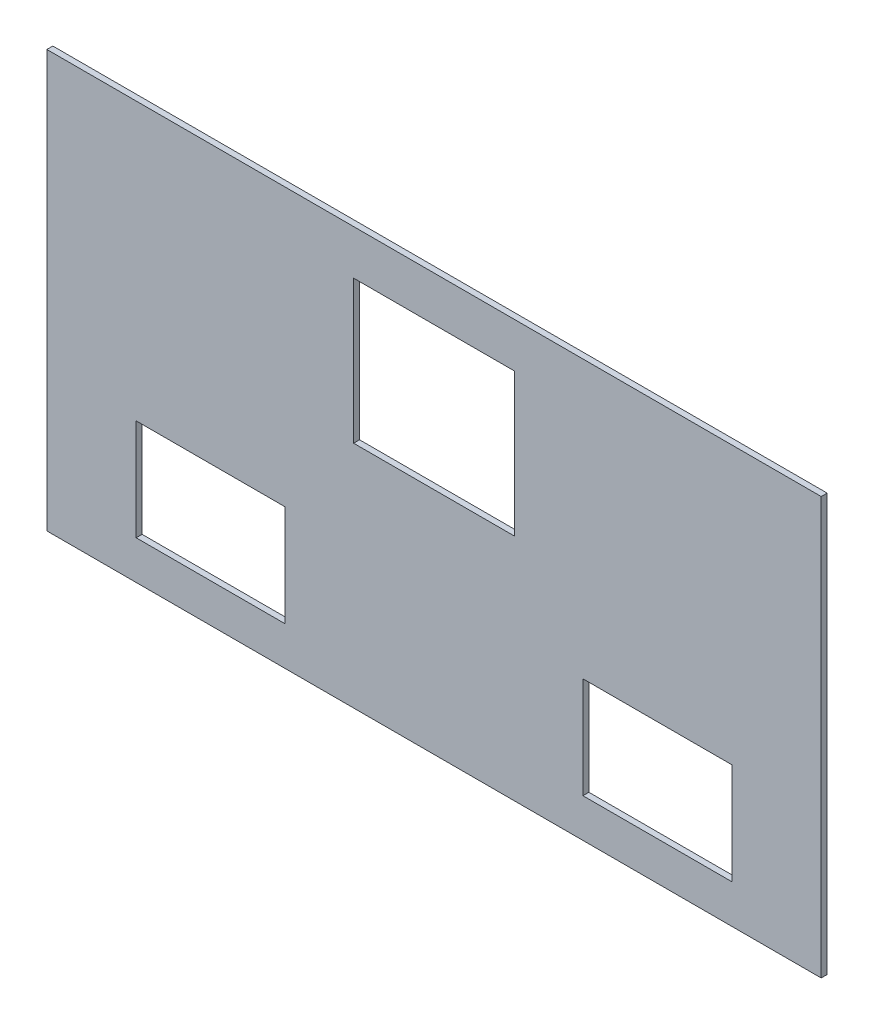
from build123d import *

# Parameters (mm, degrees)
SKETCH1_W           = 130
SKETCH1_H           = 70
BOSS_EXTRUDE1_DEPTH = 1
SKETCH2_W           = 25
SKETCH2_H           = 17
SKETCH2_W_2         = 27
SKETCH2_H_2         = 24
CUT_EXTRUDE1_DEPTH  = 2


with BuildPart() as part:
    # Sketch1 → Boss-Extrude1 (new body)
    with BuildSketch(Plane.XY):
        Rectangle(SKETCH1_W, SKETCH1_H)
    extrude(amount=BOSS_EXTRUDE1_DEPTH)

    # Sketch2 → Cut-Extrude1 (cut, through all)
    with BuildSketch(Plane.XY.offset(1)):
        with Locations((-37.5, -20)):
            Rectangle(SKETCH2_W, SKETCH2_H)
        with Locations((37.5, -20)):
            Rectangle(SKETCH2_W, SKETCH2_H)
        with Locations((0, 15.5)):
            Rectangle(SKETCH2_W_2, SKETCH2_H_2)
    extrude(amount=-CUT_EXTRUDE1_DEPTH, mode=Mode.SUBTRACT)


solid = part.part
